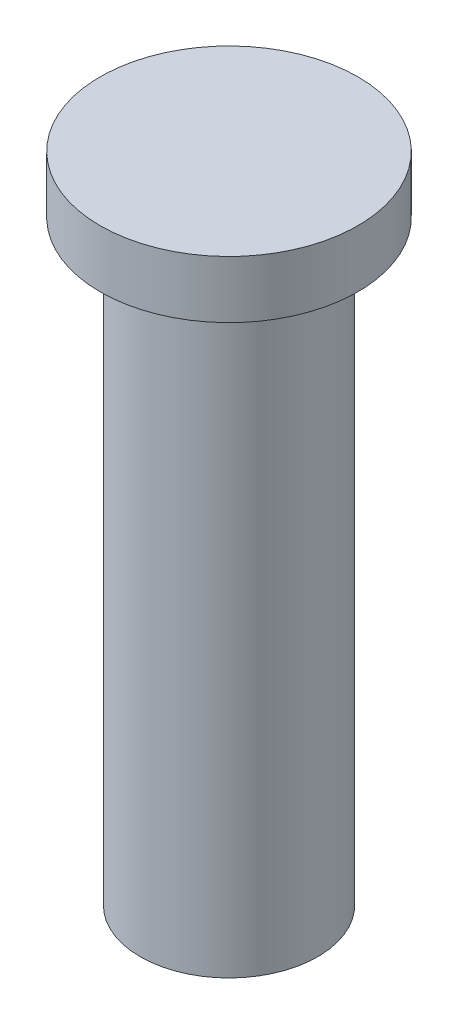
from build123d import *

# Parameters (mm, degrees)
SKETCH1_R           = 3.937
BOSS_EXTRUDE1_DEPTH = 26.416
SKETCH2_R           = 5.715
BOSS_EXTRUDE2_DEPTH = 2.54


with BuildPart() as part:
    # Sketch1 → Boss-Extrude1 (new body)
    with BuildSketch(Plane(origin=(0, 0, 0), x_dir=(1, 0, 0), z_dir=(0, 1, 0))):
        Circle(SKETCH1_R)
    extrude(amount=BOSS_EXTRUDE1_DEPTH)

    # Sketch2 → Boss-Extrude2 (add)
    with BuildSketch(Plane(origin=(0, 26.416, 0), x_dir=(1, 0, 0), z_dir=(0, 1, 0))):
        Circle(SKETCH2_R)
    extrude(amount=BOSS_EXTRUDE2_DEPTH)


solid = part.part
